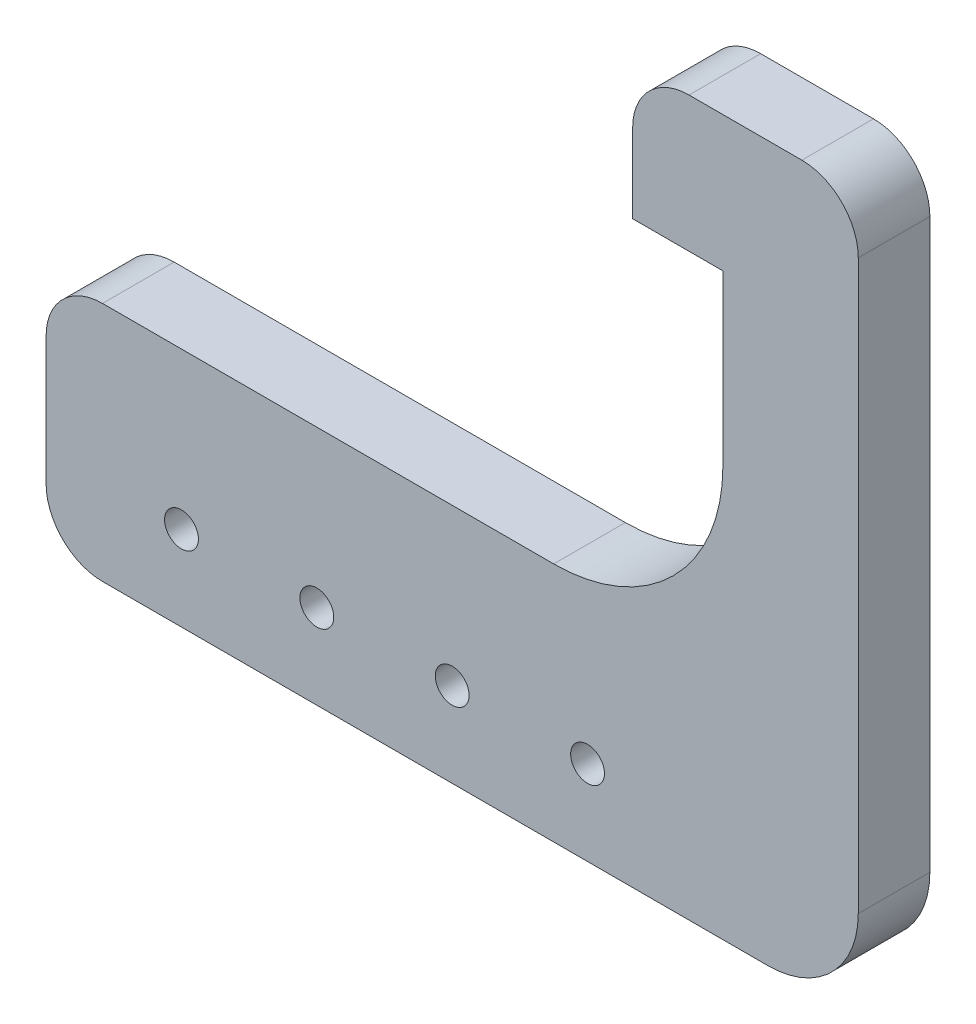
from build123d import *

# Parameters (mm, degrees)
SKETCH1_W           = 60
SKETCH1_H           = 21.35
SKETCH1_R           = 1.5
BOSS_EXTRUDE1_DEPTH = 6.35
FILLET1_R           = 15
FILLET3_R           = 5
FILLET5_R           = 5
FILLET6_R           = 5
FILLET7_R           = 8


with BuildPart() as part:
    # Sketch1 → Boss-Extrude1 (new body)
    with BuildSketch(Plane.XY):
        with Locations((30, 10.675)):
            Rectangle(SKETCH1_W, SKETCH1_H)
        with Locations((12, 7.5)):
            Circle(SKETCH1_R, mode=Mode.SUBTRACT)
        with Locations((24, 7.5)):
            Circle(SKETCH1_R, mode=Mode.SUBTRACT)
        with Locations((36, 7.5)):
            Circle(SKETCH1_R, mode=Mode.SUBTRACT)
        with Locations((48, 7.5)):
            Circle(SKETCH1_R, mode=Mode.SUBTRACT)
        Polygon((60, 21.35), (60, 0), (72, 0), (72, 51.35), (60, 51.35), align=None)
        Polygon((52, 51.35), (60, 51.35), (72, 51.35), (72, 63.35), (52, 63.35), align=None)
    extrude(amount=BOSS_EXTRUDE1_DEPTH)

    # Fillet1
    fillet1_edges = [part.edges().sort_by_distance(p)[0] for p in [
        (60, 21.35, 3.175),
    ]]
    fillet(fillet1_edges, radius=FILLET1_R)

    # Fillet3
    fillet3_edges = [part.edges().sort_by_distance(p)[0] for p in [
        (52, 63.35, 3.175),
    ]]
    fillet(fillet3_edges, radius=FILLET3_R)

    # Fillet5
    fillet5_edges = [part.edges().sort_by_distance(p)[0] for p in [
        (0, 0, 3.175),
        (0, 21.35, 3.175),
    ]]
    fillet(fillet5_edges, radius=FILLET5_R)

    # Fillet6
    fillet6_edges = [part.edges().sort_by_distance(p)[0] for p in [
        (72, 63.35, 3.175),
    ]]
    fillet(fillet6_edges, radius=FILLET6_R)

    # Fillet7
    fillet7_edges = [part.edges().sort_by_distance(p)[0] for p in [
        (72, 0, 3.175),
    ]]
    fillet(fillet7_edges, radius=FILLET7_R)


solid = part.part
